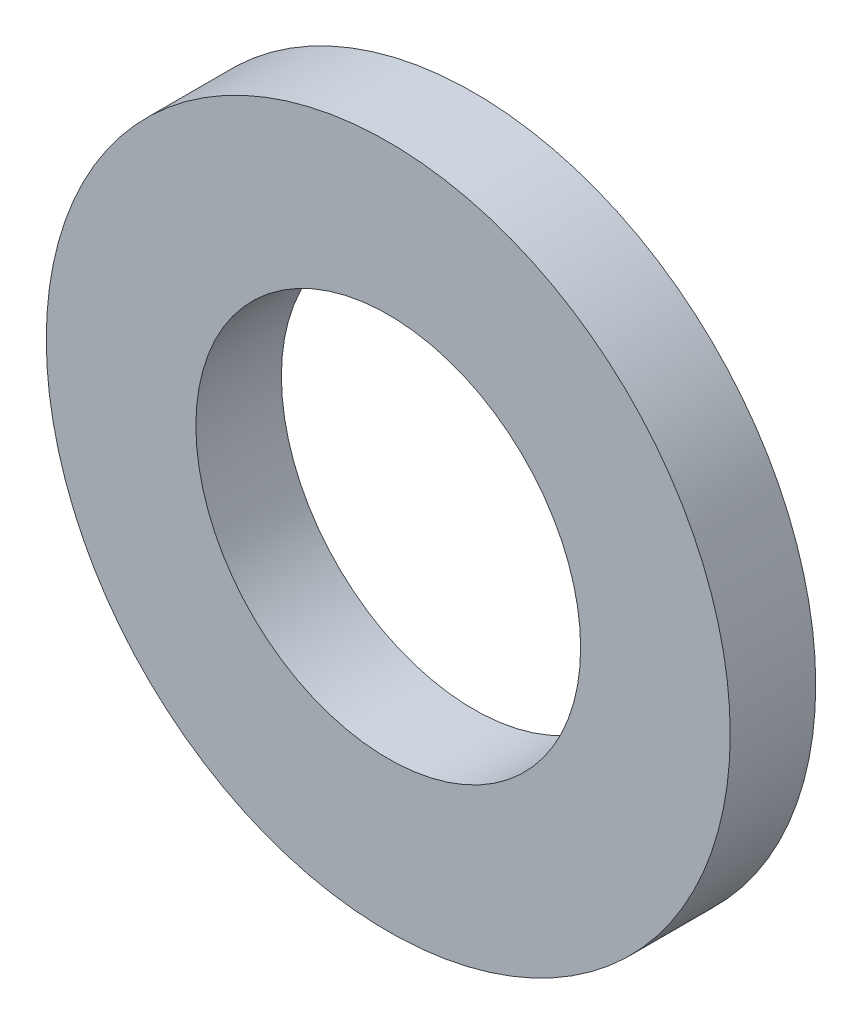
from build123d import *

# Parameters (mm, degrees)
SKETCH1_R           = 4
SKETCH1_R_2         = 2.25
BOSS_EXTRUDE1_DEPTH = 1


with BuildPart() as part:
    # Sketch1 → Boss-Extrude1 (new body)
    with BuildSketch(Plane.XY):
        Circle(SKETCH1_R)
        Circle(SKETCH1_R_2, mode=Mode.SUBTRACT)
    extrude(amount=BOSS_EXTRUDE1_DEPTH)


solid = part.part
